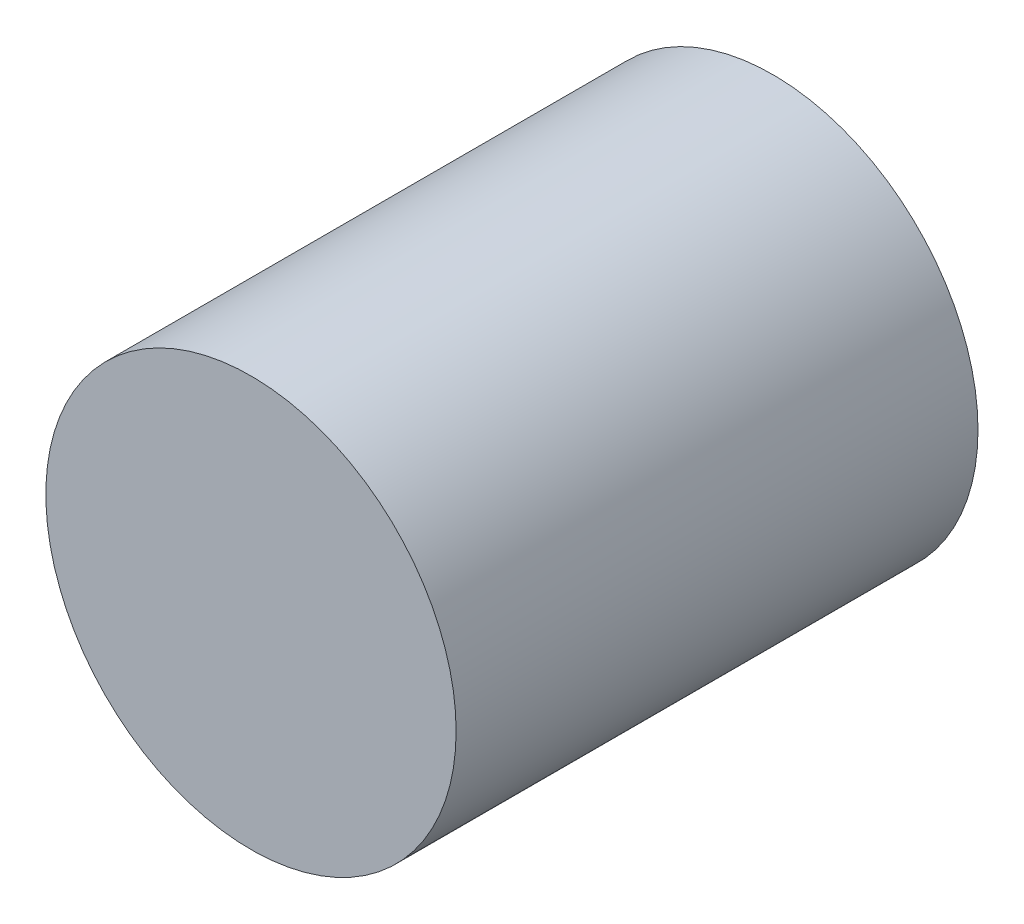
from build123d import *

# Parameters (mm, degrees)
SKETCH2_R           = 11.95
BOSS_EXTRUDE1_DEPTH = 30.4
SKETCH4_R           = 1.5
CUT_EXTRUDE2_DEPTH  = 3
SKETCH5_R           = 0.99
BOSS_EXTRUDE2_DEPTH = 6.9


with BuildPart() as part:
    # Sketch2 → Boss-Extrude1 (new body)
    with BuildSketch(Plane.XY):
        Circle(SKETCH2_R)
    extrude(amount=BOSS_EXTRUDE1_DEPTH)

    # Sketch4 → Cut-Extrude2 (cut)
    with BuildSketch(Plane(origin=(0, 0, 0), x_dir=(-1, 0, 0), z_dir=(0, 0, -1))):
        with Locations((0, 8.95)):
            Circle(SKETCH4_R)
        with Locations((0, -8.95)):
            Circle(SKETCH4_R)
    extrude(amount=-CUT_EXTRUDE2_DEPTH, mode=Mode.SUBTRACT)

    # Sketch5 → Boss-Extrude2 (add)
    with BuildSketch(Plane(origin=(0, 0, 0), x_dir=(-1, 0, 0), z_dir=(0, 0, -1))):
        Circle(SKETCH5_R)
    extrude(amount=BOSS_EXTRUDE2_DEPTH)


solid = part.part
